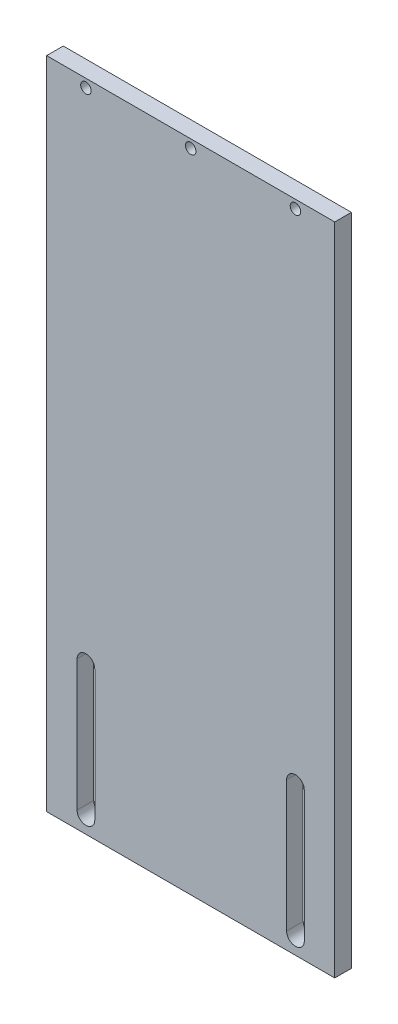
from build123d import *

# Parameters (mm, degrees)
CROQUIS1_W              = 110
CROQUIS1_H              = 250
SALIENTE_EXTRUIR1_DEPTH = 6.35
CROQUIS2_R              = 2
CORTAR_EXTRUIR2_DEPTH   = 7.35


with BuildPart() as part:
    # Croquis1 → Saliente-Extruir1 (new body)
    with BuildSketch(Plane.XY):
        Rectangle(CROQUIS1_W, CROQUIS1_H)
    extrude(amount=SALIENTE_EXTRUIR1_DEPTH)

    # Croquis2 → Cortar-Extruir2 (cut, through all)
    with BuildSketch(Plane.XY):
        with Locations((40, 121.825)):
            Circle(CROQUIS2_R)
        with Locations((-40, 121.825)):
            Circle(CROQUIS2_R)
        with Locations((0, 121.825)):
            Circle(CROQUIS2_R)
        with BuildLine():
            Line((36.625, -68.65), (36.625, -118.65))
            ThreePointArc((36.625, -118.65), (40, -122.025), (43.375, -118.65))
            Line((43.375, -118.65), (43.375, -68.65))
            ThreePointArc((43.375, -68.65), (40, -65.275), (36.625, -68.65))
        make_face()
        with BuildLine():
            Line((-43.375, -68.65), (-43.375, -118.65))
            ThreePointArc((-43.375, -118.65), (-40, -122.025), (-36.625, -118.65))
            Line((-36.625, -118.65), (-36.625, -68.65))
            ThreePointArc((-36.625, -68.65), (-40, -65.275), (-43.375, -68.65))
        make_face()
    extrude(amount=CORTAR_EXTRUIR2_DEPTH, mode=Mode.SUBTRACT)


solid = part.part
